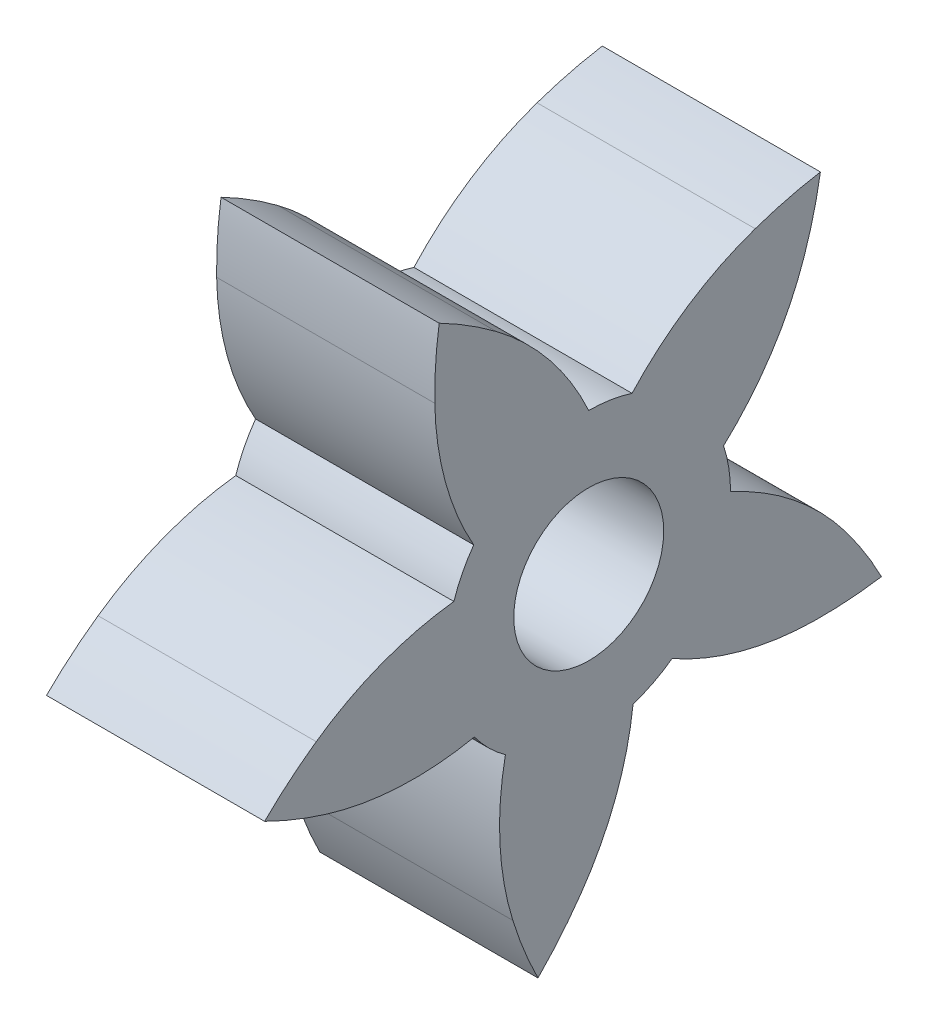
from build123d import *

# Parameters (mm, degrees)
BOSS_EXTRUDE1_DEPTH      = 4
BOSS_EXTRUDE1_DEPTH_BACK = 4
SKETCH1_R                = 2.75


with BuildPart() as part:
    # Sketch1 → Boss-Extrude1 (new, two sides: drawn at the far end of the back side and taken through both)
    with BuildSketch(Plane(origin=(0, 0, 0), x_dir=(0, 0, -1), z_dir=(1, 0, 0)).offset(-BOSS_EXTRUDE1_DEPTH_BACK)):
        with BuildLine():
            ThreePointArc((6.104566947, 7.920496348), (3.660962149, 6.718169615), (1.588390796, 4.951465912))
            ThreePointArc((1.588390796, 4.951465912), (0.803858587, 5.137490766), (0, 5.2))
            ThreePointArc((0, 5.2), (-1.433855865, 7.515351235), (-3.393406085, 9.406635697))
            ThreePointArc((-3.393406085, 9.406635697), (-4.411888917, 10.105404063), (-5.485434516, 10.716210377))
            ThreePointArc((-5.485434516, 10.716210377), (-5.617706577, 9.488167784), (-5.646424734, 8.253356149))
            ThreePointArc((-5.646424734, 8.253356149), (-5.25805947, 5.557810489), (-4.218284171, 3.040736531))
            ThreePointArc((-4.218284171, 3.040736531), (-4.637638106, 2.352086903), (-4.945493885, 1.606888371))
            ThreePointArc((-4.945493885, 1.606888371), (-7.590609594, 0.958693286), (-9.994862325, -0.32051068))
            ThreePointArc((-9.994862325, -0.32051068), (-10.974159037, -1.073214113), (-11.886814196, -1.90546712))
            ThreePointArc((-11.886814196, -1.90546712), (-10.759750601, -2.410751356), (-9.594249347, -2.819641726))
            ThreePointArc((-9.594249347, -2.819641726), (-6.910621616, -3.283253829), (-4.195433788, -3.072187385))
            ThreePointArc((-4.195433788, -3.072187385), (-3.670076564, -3.683821116), (-3.056483312, -4.206888371))
            ThreePointArc((-3.056483312, -4.206888371), (-3.257398859, -6.922846199), (-2.783758545, -9.604722191))
            ThreePointArc((-2.783758545, -9.604722191), (-2.370514366, -10.768686862), (-1.861020675, -11.893853821))
            ThreePointArc((-1.861020675, -11.893853821), (-1.032185004, -10.978094061), (-0.283147459, -9.995990572))
            ThreePointArc((-0.283147459, -9.995990572), (0.987060428, -7.586972949), (1.625363492, -4.939452755))
            ThreePointArc((1.625363492, -4.939452755), (2.369406048, -4.628813561), (3.056483312, -4.206888371))
            ThreePointArc((3.056483312, -4.206888371), (5.577426384, -5.237247536), (8.274404928, -5.615534087))
            ThreePointArc((8.274404928, -5.615534087), (9.509100588, -5.582200382), (10.736640165, -5.445338799))
            ThreePointArc((10.736640165, -5.445338799), (10.121825185, -4.374083905), (9.419254594, -3.358220198))
            ThreePointArc((9.419254594, -3.358220198), (7.520658509, -1.405753325), (5.199963671, 0.019437697))
            ThreePointArc((5.199963671, 0.019437697), (5.134450035, 0.823057007), (4.945493885, 1.606888371))
            ThreePointArc((4.945493885, 1.606888371), (6.704437934, 3.686049214), (7.897622027, 6.13413126))
            ThreePointArc((7.897622027, 6.13413126), (8.247461732, 7.318697294), (8.496629222, 8.528449363))
            ThreePointArc((8.496629222, 8.528449363), (7.287816997, 8.274761538), (6.104566947, 7.920496348))
        make_face()
        Circle(SKETCH1_R, mode=Mode.SUBTRACT)
    extrude(amount=BOSS_EXTRUDE1_DEPTH + BOSS_EXTRUDE1_DEPTH_BACK)


solid = part.part
